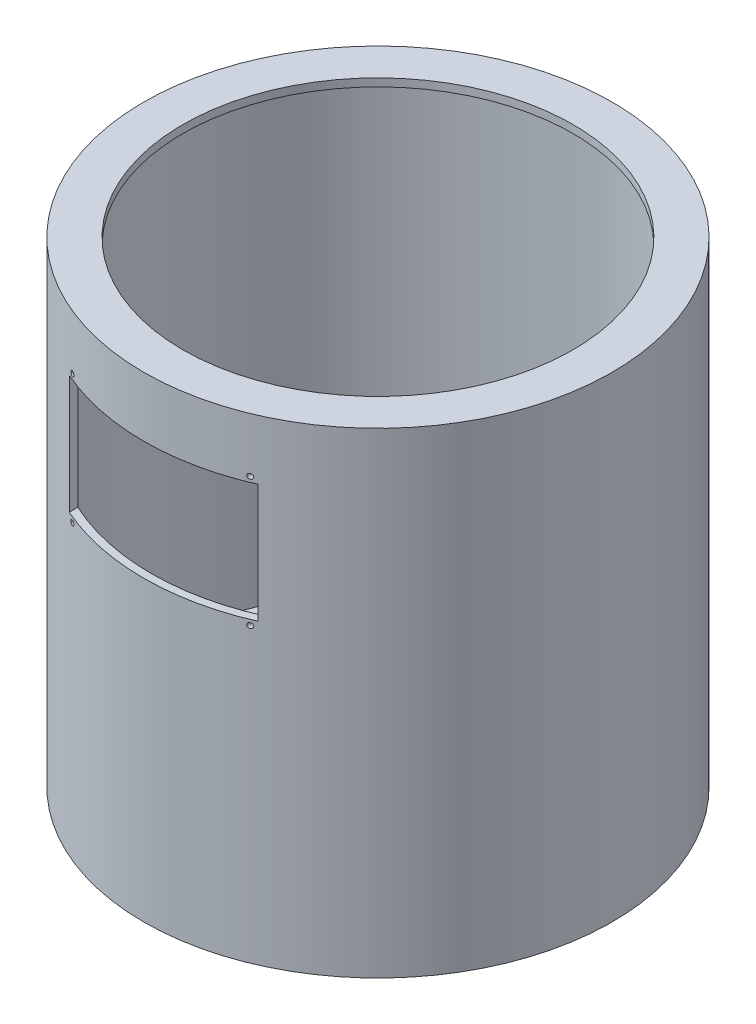
from build123d import *

# Parameters (mm, degrees)
SKETCH1_R           = 150
SKETCH1_R_2         = 125
BOSS_EXTRUDE1_DEPTH = 5
SKETCH2_R           = 150
SKETCH2_R_2         = 145
BOSS_EXTRUDE2_DEPTH = 300
SKETCH3_R           = 150
SKETCH3_R_2         = 125
BOSS_EXTRUDE3_DEPTH = 5
CUT_EXTRUDE1_REACH  = 152
SKETCH5_W           = 121
SKETCH5_H           = 76
CUT_EXTRUDE2_REACH  = 152
SKETCH7_R           = 1.6


with BuildPart() as part:
    # Sketch1 → Boss-Extrude1 (new body)
    with BuildSketch(Plane(origin=(0, 0, 0), x_dir=(1, 0, 0), z_dir=(0, 1, 0))):
        Circle(SKETCH1_R)
        Circle(SKETCH1_R_2, mode=Mode.SUBTRACT)
    extrude(amount=BOSS_EXTRUDE1_DEPTH)

    # Sketch2 → Boss-Extrude2 (add)
    with BuildSketch(Plane(origin=(0, 5, 0), x_dir=(1, 0, 0), z_dir=(0, 1, 0))):
        Circle(SKETCH2_R)
        Circle(SKETCH2_R_2, mode=Mode.SUBTRACT)
    extrude(amount=BOSS_EXTRUDE2_DEPTH)

    # Sketch3 → Boss-Extrude3 (add)
    with BuildSketch(Plane(origin=(0, 305, 0), x_dir=(1, 0, 0), z_dir=(0, 1, 0))):
        Circle(SKETCH3_R)
        Circle(SKETCH3_R_2, mode=Mode.SUBTRACT)
    extrude(amount=-BOSS_EXTRUDE3_DEPTH)

    # Sketch5 → Cut-Extrude1 (cut, up to next)
    with BuildSketch(Plane.XY, mode=Mode.PRIVATE) as cut_extrude1_sk1:
        with Locations((0, 228.75)):
            Rectangle(SKETCH5_W, SKETCH5_H)
    cut_extrude1_tool1 = extrude(cut_extrude1_sk1.sketch, amount=CUT_EXTRUDE1_REACH, mode=Mode.PRIVATE) & part.part
    add(cut_extrude1_tool1.solids().sort_by_distance((0, 228.75, 0))[0], mode=Mode.SUBTRACT)

    # Sketch7 → Cut-Extrude2 (cut, up to next)
    with BuildSketch(Plane.XY, mode=Mode.PRIVATE) as cut_extrude2_sk1:
        with Locations((56.95, 270.15)):
            Circle(SKETCH7_R)
    cut_extrude2_tool1 = extrude(cut_extrude2_sk1.sketch, amount=CUT_EXTRUDE2_REACH, mode=Mode.PRIVATE) & part.part
    add(cut_extrude2_tool1.solids().sort_by_distance((56.95, 270.15, 0))[0], mode=Mode.SUBTRACT)
    # Sketch7 → Cut-Extrude2 (cut, up to next)
    with BuildSketch(Plane.XY, mode=Mode.PRIVATE) as cut_extrude2_sk2:
        with Locations((56.95, 187.35)):
            Circle(SKETCH7_R)
    cut_extrude2_tool2 = extrude(cut_extrude2_sk2.sketch, amount=CUT_EXTRUDE2_REACH, mode=Mode.PRIVATE) & part.part
    add(cut_extrude2_tool2.solids().sort_by_distance((56.95, 187.35, 0))[0], mode=Mode.SUBTRACT)
    # Sketch7 → Cut-Extrude2 (cut, up to next)
    with BuildSketch(Plane.XY, mode=Mode.PRIVATE) as cut_extrude2_sk3:
        with Locations((-56.95, 270.15)):
            Circle(SKETCH7_R)
    cut_extrude2_tool3 = extrude(cut_extrude2_sk3.sketch, amount=CUT_EXTRUDE2_REACH, mode=Mode.PRIVATE) & part.part
    add(cut_extrude2_tool3.solids().sort_by_distance((-56.95, 270.15, 0))[0], mode=Mode.SUBTRACT)
    # Sketch7 → Cut-Extrude2 (cut, up to next)
    with BuildSketch(Plane.XY, mode=Mode.PRIVATE) as cut_extrude2_sk4:
        with Locations((-56.95, 187.35)):
            Circle(SKETCH7_R)
    cut_extrude2_tool4 = extrude(cut_extrude2_sk4.sketch, amount=CUT_EXTRUDE2_REACH, mode=Mode.PRIVATE) & part.part
    add(cut_extrude2_tool4.solids().sort_by_distance((-56.95, 187.35, 0))[0], mode=Mode.SUBTRACT)


solid = part.part
